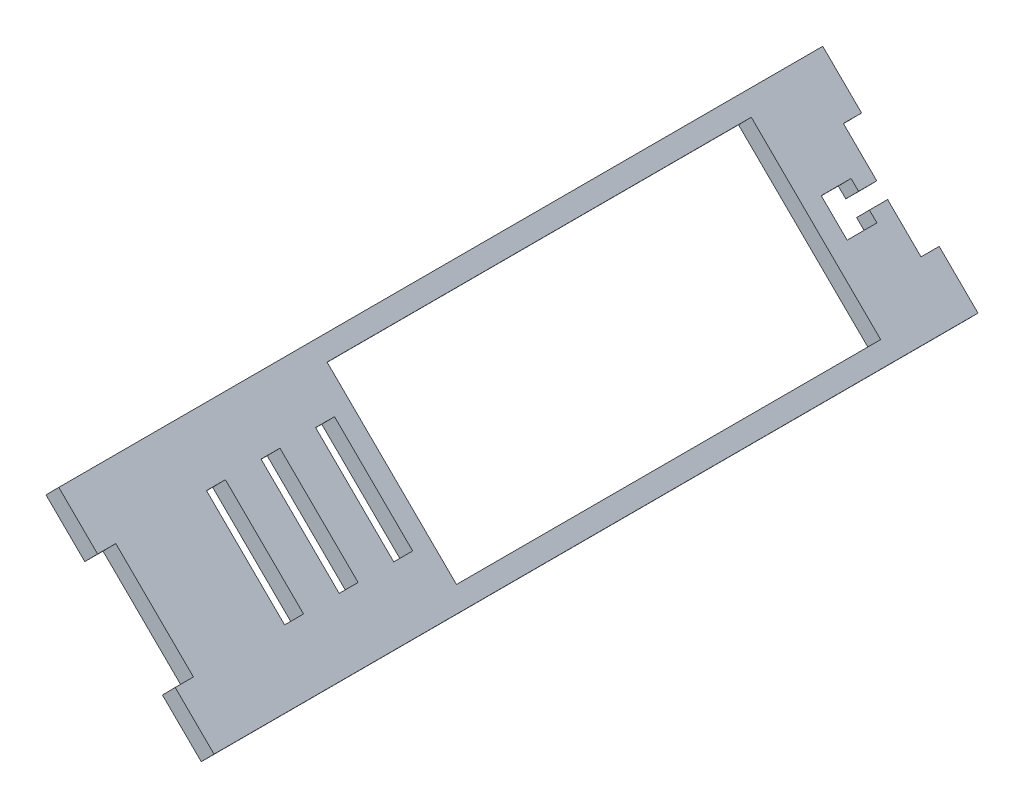
from build123d import *

# Parameters (mm, degrees)
BOSS_EXTRUDE1_DEPTH = 200
SKETCH3_W           = 15
SKETCH3_H           = 5
BOSS_EXTRUDE2_DEPTH = 5
SKETCH4_W           = 30.2
SKETCH4_H           = 5.2
CUT_EXTRUDE1_DEPTH  = 5
SKETCH5_W           = 4.2
SKETCH5_H           = 5
CUT_EXTRUDE2_DEPTH  = 10
SKETCH6_W           = 50
SKETCH6_H           = 116.6
CUT_EXTRUDE3_DEPTH  = 10


with BuildPart() as part:
    # Sketch1 → Boss-Extrude1 (new body)
    with BuildSketch(Plane.XY):
        Polygon((34.899243254, 77.987452967), (77.573371526, 35.810222425), (81.088140738, 39.366399781), (38.414012466, 81.543630323), align=None)
    extrude(amount=BOSS_EXTRUDE1_DEPTH)

    # Sketch3 → Boss-Extrude2 (add)
    with BuildSketch(Plane(origin=(56.23630739, 56.898837696, 0), x_dir=(0.711235471, -0.702953842, 0), z_dir=(-0.702953842, -0.711235471, 0))):
        with Locations((-22.5, 202.5)):
            Rectangle(SKETCH3_W, SKETCH3_H)
        with Locations((22.5, 202.5)):
            Rectangle(SKETCH3_W, SKETCH3_H)
        with Locations((22.5, -2.5)):
            Rectangle(SKETCH3_W, SKETCH3_H)
        with Locations((-22.5, -2.5)):
            Rectangle(SKETCH3_W, SKETCH3_H)
    extrude(amount=-BOSS_EXTRUDE2_DEPTH)

    # Sketch4 → Cut-Extrude1 (cut)
    with BuildSketch(Plane(origin=(56.23630739, 56.898837696, 0), x_dir=(0.711235471, -0.702953842, 0), z_dir=(-0.702953842, -0.711235471, 0))):
        with Locations((0, 172.4)):
            Rectangle(SKETCH4_W, SKETCH4_H)
        with Locations((0, 157.4)):
            Rectangle(SKETCH4_W, SKETCH4_H)
        with Locations((0, 142.4)):
            Rectangle(SKETCH4_W, SKETCH4_H)
    extrude(amount=-CUT_EXTRUDE1_DEPTH, mode=Mode.SUBTRACT)

    # Sketch5 → Cut-Extrude2 (cut)
    with BuildSketch(Plane(origin=(59.751076602, 60.455015052, 0), x_dir=(0.711235471, -0.702953842, 0), z_dir=(0.702953842, 0.711235471, 0))):
        Polygon((2.1, -5), (-2.1, -5), (-5, -5), (-5, -13.2), (5, -13.2), (5, -5), align=None)
        with Locations((0, -2.5)):
            Rectangle(SKETCH5_W, SKETCH5_H)
    extrude(amount=-CUT_EXTRUDE2_DEPTH, mode=Mode.SUBTRACT)

    # Sketch6 → Cut-Extrude3 (cut)
    with BuildSketch(Plane(origin=(59.751076602, 60.455015052, 0), x_dir=(0.711235471, -0.702953842, 0), z_dir=(0.702953842, 0.711235471, 0))):
        with Locations((0, -76.5)):
            Rectangle(SKETCH6_W, SKETCH6_H)
    extrude(amount=-CUT_EXTRUDE3_DEPTH, mode=Mode.SUBTRACT)


solid = part.part
